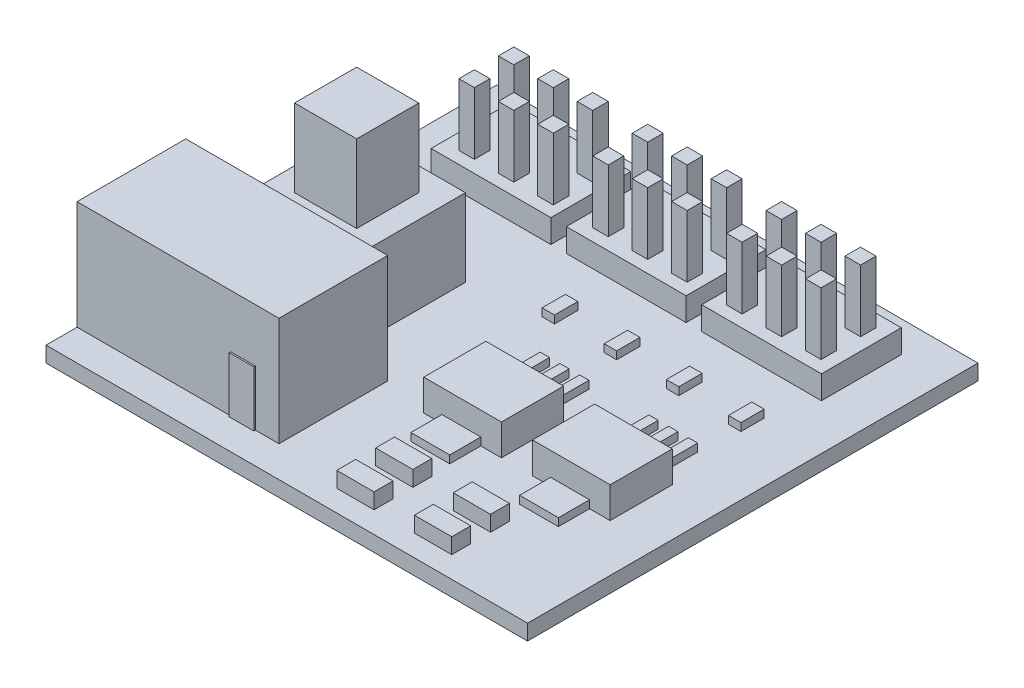
from build123d import *

# Parameters (mm, degrees)
SKETCH1_W            = 31
SKETCH1_H            = 29
BOSS_EXTRUDE1_DEPTH  = 1
SKETCH2_W            = 7
SKETCH2_H            = 8
BOSS_EXTRUDE2_DEPTH  = 13
SKETCH3_W            = 7
SKETCH3_H            = 7
BOSS_EXTRUDE3_DEPTH  = 5
SKETCH4_W            = 4
SKETCH4_H            = 4
BOSS_EXTRUDE4_DEPTH  = 5
SKETCH5_R            = 2.75
CUT_EXTRUDE1_DEPTH   = 8
SKETCH6_W            = 1.591238362
SKETCH6_H            = 3.57435367
BOSS_EXTRUDE5_DEPTH  = 0.1
SKETCH7_R            = 0.879599875
BOSS_EXTRUDE6_DEPTH  = 8
FILLET2_R            = 0.5
SKETCH8_W            = 7.71
SKETCH8_H            = 5.14
BOSS_EXTRUDE7_DEPTH  = 1.5
SKETCH9_W            = 1
SKETCH9_H            = 1
BOSS_EXTRUDE8_DEPTH  = 4
SKETCH10_W           = 0.8
SKETCH10_H           = 1.5
BOSS_EXTRUDE9_DEPTH  = 0.5
SKETCH11_W           = 5
SKETCH11_H           = 4
BOSS_EXTRUDE10_DEPTH = 2
SKETCH12_W           = 0.6
SKETCH12_H           = 2.642715267
BOSS_EXTRUDE11_DEPTH = 0.5
SKETCH13_W           = 2.5
SKETCH13_H           = 2
BOSS_EXTRUDE12_DEPTH = 0.5
SKETCH14_W           = 2.401106116
SKETCH14_H           = 1.2192983
BOSS_EXTRUDE13_DEPTH = 1


with BuildPart() as part:
    # Sketch1 → Boss-Extrude1 (new body)
    with BuildSketch(Plane(origin=(0, 0, 0), x_dir=(1, 0, 0), z_dir=(0, 1, 0))):
        with Locations((15.5, 14.5)):
            Rectangle(SKETCH1_W, SKETCH1_H)
    extrude(amount=BOSS_EXTRUDE1_DEPTH)

    # Sketch2 → Boss-Extrude2 (add)
    with BuildSketch(Plane.ZY):
        with Locations((-5.5, 4)):
            Rectangle(SKETCH2_W, SKETCH2_H)
    extrude(amount=-BOSS_EXTRUDE2_DEPTH)

    # Sketch3 → Boss-Extrude3 (add)
    with BuildSketch(Plane(origin=(0, 1, 0), x_dir=(1, 0, 0), z_dir=(0, 1, 0))):
        with Locations((6.5, 13.5)):
            Rectangle(SKETCH3_W, SKETCH3_H)
    extrude(amount=BOSS_EXTRUDE3_DEPTH)

    # Sketch4 → Boss-Extrude4 (add)
    with BuildSketch(Plane(origin=(0, 6, 0), x_dir=(1, 0, 0), z_dir=(0, 1, 0))):
        with Locations((6.5, 13.5)):
            Rectangle(SKETCH4_W, SKETCH4_H)
    extrude(amount=BOSS_EXTRUDE4_DEPTH)

    # Sketch5 → Cut-Extrude1 (cut)
    with BuildSketch(Plane.ZY):
        with Locations((-5.5, 4.5)):
            Circle(SKETCH5_R)
    extrude(amount=-CUT_EXTRUDE1_DEPTH, mode=Mode.SUBTRACT)

    # Sketch6 → Boss-Extrude5 (add)
    with BuildSketch(Plane.XY.offset(-2)):
        with Locations((10.684219388, 2.787176835)):
            Rectangle(SKETCH6_W, SKETCH6_H)
    extrude(amount=BOSS_EXTRUDE5_DEPTH)

    # Sketch7 → Boss-Extrude6 (add)
    with BuildSketch(Plane.ZY.offset(-8)):
        with Locations((-5.5, 4.5)):
            Circle(SKETCH7_R)
    extrude(amount=BOSS_EXTRUDE6_DEPTH)

    # Fillet2
    fillet2_edges = [part.edges().sort_by_distance(p)[0] for p in [
        (0, 4.5, -6.379599875),
    ]]
    fillet(fillet2_edges, radius=FILLET2_R)

    # Sketch8 → Boss-Extrude7 (add)
    with BuildSketch(Plane(origin=(0, 1, 0), x_dir=(1, 0, 0), z_dir=(0, 1, 0))):
        with Locations((15.495, 24.43)):
            Rectangle(SKETCH8_W, SKETCH8_H)
        with Locations((6.785, 24.43)):
            Rectangle(SKETCH8_W, SKETCH8_H)
        with Locations((24.205, 24.43)):
            Rectangle(SKETCH8_W, SKETCH8_H)
    extrude(amount=BOSS_EXTRUDE7_DEPTH)

    # Sketch9 → Boss-Extrude8 (add)
    with BuildSketch(Plane(origin=(0, 2.5, 0), x_dir=(1, 0, 0), z_dir=(0, 1, 0))):
        with Locations((6.971468334, 25.685)):
            Rectangle(SKETCH9_W, SKETCH9_H)
        with Locations((4.431468334, 25.685)):
            Rectangle(SKETCH9_W, SKETCH9_H)
        with Locations((9.511468334, 25.685)):
            Rectangle(SKETCH9_W, SKETCH9_H)
        with Locations((4.431468334, 23.145)):
            Rectangle(SKETCH9_W, SKETCH9_H)
        with Locations((13.051468334, 23.145)):
            Rectangle(SKETCH9_W, SKETCH9_H)
        with Locations((6.971468334, 23.145)):
            Rectangle(SKETCH9_W, SKETCH9_H)
        with Locations((9.511468334, 23.145)):
            Rectangle(SKETCH9_W, SKETCH9_H)
        with Locations((18.131468334, 25.685)):
            Rectangle(SKETCH9_W, SKETCH9_H)
        with Locations((18.131468334, 23.145)):
            Rectangle(SKETCH9_W, SKETCH9_H)
        with Locations((15.591468334, 23.145)):
            Rectangle(SKETCH9_W, SKETCH9_H)
        with Locations((15.591468334, 25.685)):
            Rectangle(SKETCH9_W, SKETCH9_H)
        with Locations((13.051468334, 25.685)):
            Rectangle(SKETCH9_W, SKETCH9_H)
        with Locations((21.671468334, 23.145)):
            Rectangle(SKETCH9_W, SKETCH9_H)
        with Locations((26.751468334, 25.685)):
            Rectangle(SKETCH9_W, SKETCH9_H)
        with Locations((26.751468334, 23.145)):
            Rectangle(SKETCH9_W, SKETCH9_H)
        with Locations((24.211468334, 23.145)):
            Rectangle(SKETCH9_W, SKETCH9_H)
        with Locations((24.211468334, 25.685)):
            Rectangle(SKETCH9_W, SKETCH9_H)
        with Locations((21.671468334, 25.685)):
            Rectangle(SKETCH9_W, SKETCH9_H)
    extrude(amount=BOSS_EXTRUDE8_DEPTH)

    # Sketch10 → Boss-Extrude9 (add)
    with BuildSketch(Plane(origin=(0, 1, 0), x_dir=(1, 0, 0), z_dir=(0, 1, 0))):
        with Locations((18.786083485, 18.300770285)):
            Rectangle(SKETCH10_W, SKETCH10_H)
        with Locations((14.786083485, 18.300770285)):
            Rectangle(SKETCH10_W, SKETCH10_H)
        with Locations((22.786083485, 18.300770285)):
            Rectangle(SKETCH10_W, SKETCH10_H)
        with Locations((26.786083485, 18.300770285)):
            Rectangle(SKETCH10_W, SKETCH10_H)
    extrude(amount=BOSS_EXTRUDE9_DEPTH)

    # Sketch11 → Boss-Extrude10 (add)
    with BuildSketch(Plane(origin=(0, 1, 0), x_dir=(1, 0, 0), z_dir=(0, 1, 0))):
        with Locations((25.443805994, 10.374755585)):
            Rectangle(SKETCH11_W, SKETCH11_H)
        with Locations((18.443805994, 10.374755585)):
            Rectangle(SKETCH11_W, SKETCH11_H)
    extrude(amount=BOSS_EXTRUDE10_DEPTH)

    # Sketch12 → Boss-Extrude11 (add)
    with BuildSketch(Plane(origin=(0, 1, 0), x_dir=(1, 0, 0), z_dir=(0, 1, 0))):
        with Locations((17.095277575, 13.696113219)):
            Rectangle(SKETCH12_W, SKETCH12_H)
        with Locations((24.095277575, 13.696113219)):
            Rectangle(SKETCH12_W, SKETCH12_H)
        with Locations((18.365277575, 13.696113219)):
            Rectangle(SKETCH12_W, SKETCH12_H)
        with Locations((19.635277575, 13.696113219)):
            Rectangle(SKETCH12_W, SKETCH12_H)
        with Locations((25.365277575, 13.696113219)):
            Rectangle(SKETCH12_W, SKETCH12_H)
        with Locations((26.635277575, 13.696113219)):
            Rectangle(SKETCH12_W, SKETCH12_H)
    extrude(amount=BOSS_EXTRUDE11_DEPTH)

    # Sketch13 → Boss-Extrude12 (add)
    with BuildSketch(Plane(origin=(0, 1, 0), x_dir=(1, 0, 0), z_dir=(0, 1, 0))):
        with Locations((18.365277575, 7.374755585)):
            Rectangle(SKETCH13_W, SKETCH13_H)
        with Locations((25.365277575, 7.374755585)):
            Rectangle(SKETCH13_W, SKETCH13_H)
    extrude(amount=BOSS_EXTRUDE12_DEPTH)

    # Sketch14 → Boss-Extrude13 (add)
    with BuildSketch(Plane(origin=(0, 1, 0), x_dir=(1, 0, 0), z_dir=(0, 1, 0))):
        with Locations((23.540566393, 4.488126974)):
            Rectangle(SKETCH14_W, SKETCH14_H)
        with Locations((18.540566393, 4.488126974)):
            Rectangle(SKETCH14_W, SKETCH14_H)
        with Locations((23.540566393, 1.988126974)):
            Rectangle(SKETCH14_W, SKETCH14_H)
        with Locations((18.540566393, 1.988126974)):
            Rectangle(SKETCH14_W, SKETCH14_H)
    extrude(amount=BOSS_EXTRUDE13_DEPTH)


solid = part.part
